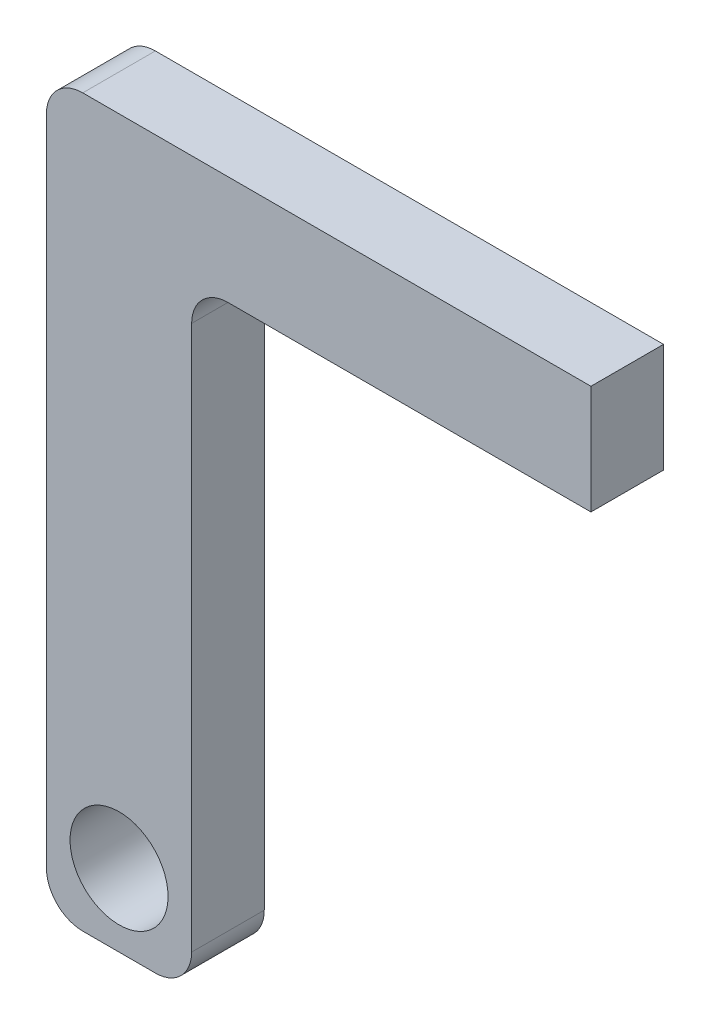
from build123d import *

# Parameters (mm, degrees)
SKETCH1_W           = 40
SKETCH1_H           = 170
BOSS_EXTRUDE1_DEPTH = 20
SKETCH2_W           = 150
SKETCH2_H           = 20
BOSS_EXTRUDE2_DEPTH = 30
FILLET1_R           = 10
CUT_EXTRUDE1_REACH  = 22
SKETCH3_R           = 13.5
FILLET2_R           = 10


with BuildPart() as part:
    # Sketch1 → Boss-Extrude1 (new body)
    with BuildSketch(Plane.XY):
        Rectangle(SKETCH1_W, SKETCH1_H)
    extrude(amount=BOSS_EXTRUDE1_DEPTH)

    # Sketch2 → Boss-Extrude2 (add)
    with BuildSketch(Plane(origin=(0, 85, 0), x_dir=(1, 0, 0), z_dir=(0, 1, 0))):
        with Locations((55, -10)):
            Rectangle(SKETCH2_W, SKETCH2_H)
    extrude(amount=BOSS_EXTRUDE2_DEPTH)

    # Fillet1
    fillet1_edges = [part.edges().sort_by_distance(p)[0] for p in [
        (20, -85, 10),
        (-20, -85, 10),
        (-20, 115, 10),
    ]]
    fillet(fillet1_edges, radius=FILLET1_R)

    # Sketch3 → Cut-Extrude1 (cut, up to next)
    with BuildSketch(Plane.XY.offset(20), mode=Mode.PRIVATE) as cut_extrude1_sk1:
        with Locations((0, -65)):
            Circle(SKETCH3_R)
    cut_extrude1_tool1 = extrude(cut_extrude1_sk1.sketch, amount=-CUT_EXTRUDE1_REACH, mode=Mode.PRIVATE) & part.part
    add(cut_extrude1_tool1.solids().sort_by_distance((0, -65, 20))[0], mode=Mode.SUBTRACT)

    # Fillet2
    fillet2_edges = [part.edges().sort_by_distance(p)[0] for p in [
        (20, 85, 10),
    ]]
    fillet(fillet2_edges, radius=FILLET2_R)


solid = part.part
